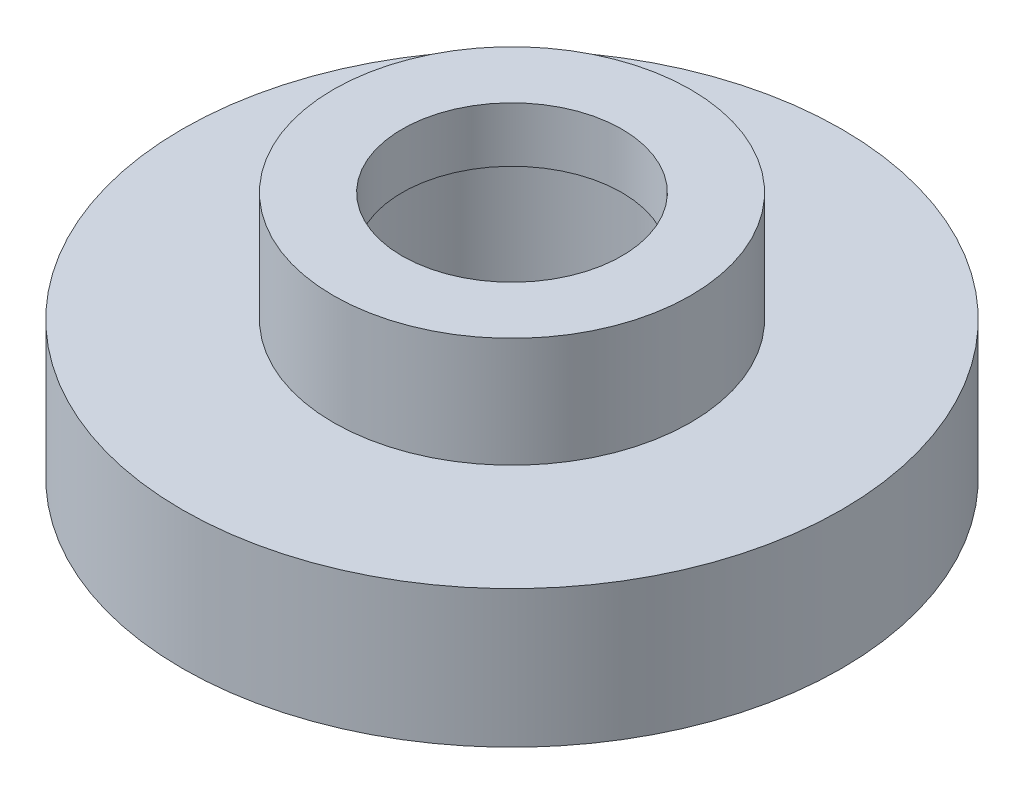
from build123d import *

# Parameters (mm, degrees)
SKETCH1_R           = 12
BOSS_EXTRUDE1_DEPTH = 5
SKETCH2_R           = 6.5
BOSS_EXTRUDE2_DEPTH = 4
SKETCH3_R           = 5.1
CUT_EXTRUDE1_DEPTH  = 7
SKETCH4_R           = 4
CUT_EXTRUDE2_DEPTH  = 7


with BuildPart() as part:
    # Sketch1 → Boss-Extrude1 (new body)
    with BuildSketch(Plane(origin=(0, 0, 0), x_dir=(1, 0, 0), z_dir=(0, 1, 0))):
        Circle(SKETCH1_R)
    extrude(amount=BOSS_EXTRUDE1_DEPTH)

    # Sketch2 → Boss-Extrude2 (add)
    with BuildSketch(Plane(origin=(0, 5, 0), x_dir=(1, 0, 0), z_dir=(0, 1, 0))):
        Circle(SKETCH2_R)
    extrude(amount=BOSS_EXTRUDE2_DEPTH)

    # Sketch3 → Cut-Extrude1 (cut)
    with BuildSketch(Plane.XZ):
        Circle(SKETCH3_R)
    extrude(amount=-CUT_EXTRUDE1_DEPTH, mode=Mode.SUBTRACT)

    # Sketch4 → Cut-Extrude2 (cut)
    with BuildSketch(Plane(origin=(0, 9, 0), x_dir=(1, 0, 0), z_dir=(0, 1, 0))):
        Circle(SKETCH4_R)
    extrude(amount=-CUT_EXTRUDE2_DEPTH, mode=Mode.SUBTRACT)


solid = part.part
